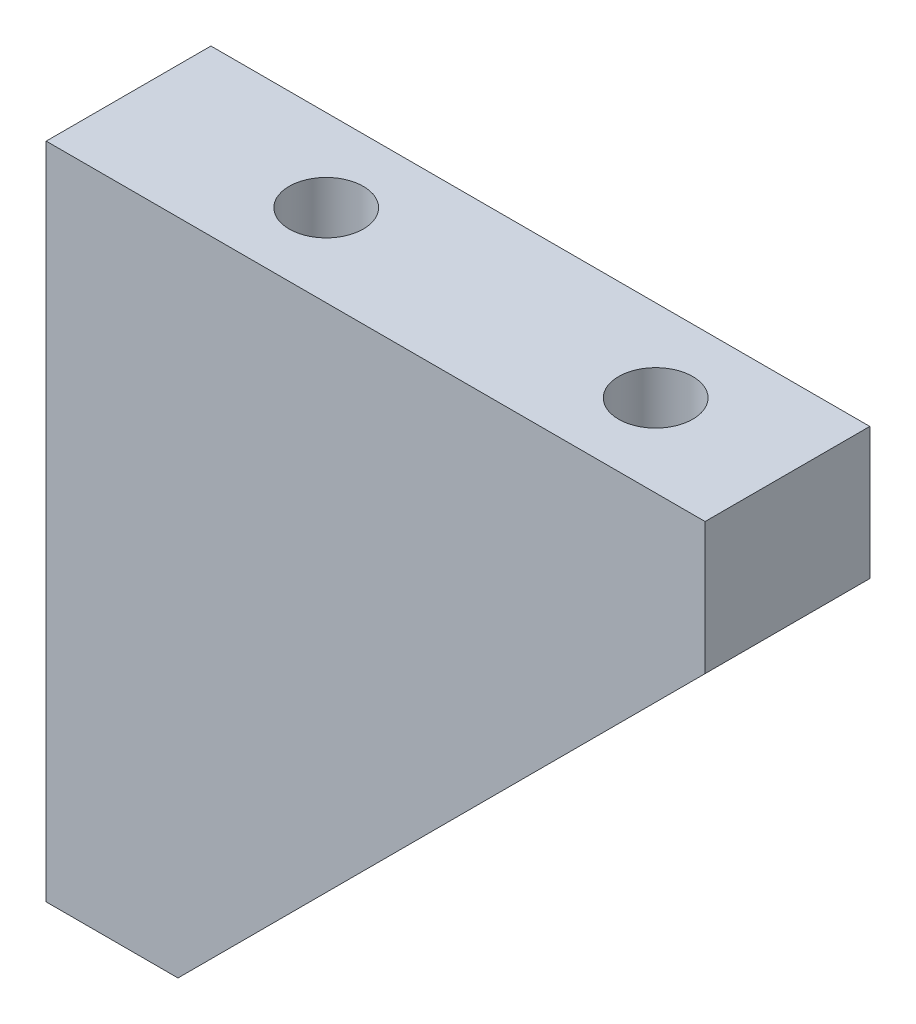
from build123d import *

# Parameters (mm, degrees)
SALIENTE_EXTRUIR1_DEPTH          = 10
TALADRO_DE_MARGEN_PARA_M41_D     = 4.5
TALADRO_DE_MARGEN_PARA_M41_DEPTH = 10
TALADRO_DE_MARGEN_PARA_M41_TIP   = 1.351936393
TALADRO_DE_MARGEN_PARA_M42_D     = 4.5
TALADRO_DE_MARGEN_PARA_M42_DEPTH = 10
TALADRO_DE_MARGEN_PARA_M42_TIP   = 1.351936393


with BuildPart() as part:
    # Croquis1 → Saliente-Extruir1 (new body)
    with BuildSketch(Plane.XY):
        Polygon((40, -8), (8, -40), (0, -40), (0, 0), (40, 0), align=None)
    extrude(amount=SALIENTE_EXTRUIR1_DEPTH)

    # Taladro de margen para M41
    with Locations(Plane(origin=(0, 0, 0), x_dir=(1, 0, 0), z_dir=(0, 1, 0))):
        with Locations((12, -5), (32, -5)):
            Hole(TALADRO_DE_MARGEN_PARA_M41_D / 2, depth=TALADRO_DE_MARGEN_PARA_M41_DEPTH)
            with Locations((0, 0, -(TALADRO_DE_MARGEN_PARA_M41_DEPTH + TALADRO_DE_MARGEN_PARA_M41_TIP / 2))):  # 118° drill point
                Cone(0, TALADRO_DE_MARGEN_PARA_M41_D / 2, TALADRO_DE_MARGEN_PARA_M41_TIP, mode=Mode.SUBTRACT)

    # Taladro de margen para M42
    with Locations(Plane.ZY):
        with Locations((5, -12), (5, -32)):
            Hole(TALADRO_DE_MARGEN_PARA_M42_D / 2, depth=TALADRO_DE_MARGEN_PARA_M42_DEPTH)
            with Locations((0, 0, -(TALADRO_DE_MARGEN_PARA_M42_DEPTH + TALADRO_DE_MARGEN_PARA_M42_TIP / 2))):  # 118° drill point
                Cone(0, TALADRO_DE_MARGEN_PARA_M42_D / 2, TALADRO_DE_MARGEN_PARA_M42_TIP, mode=Mode.SUBTRACT)


solid = part.part
